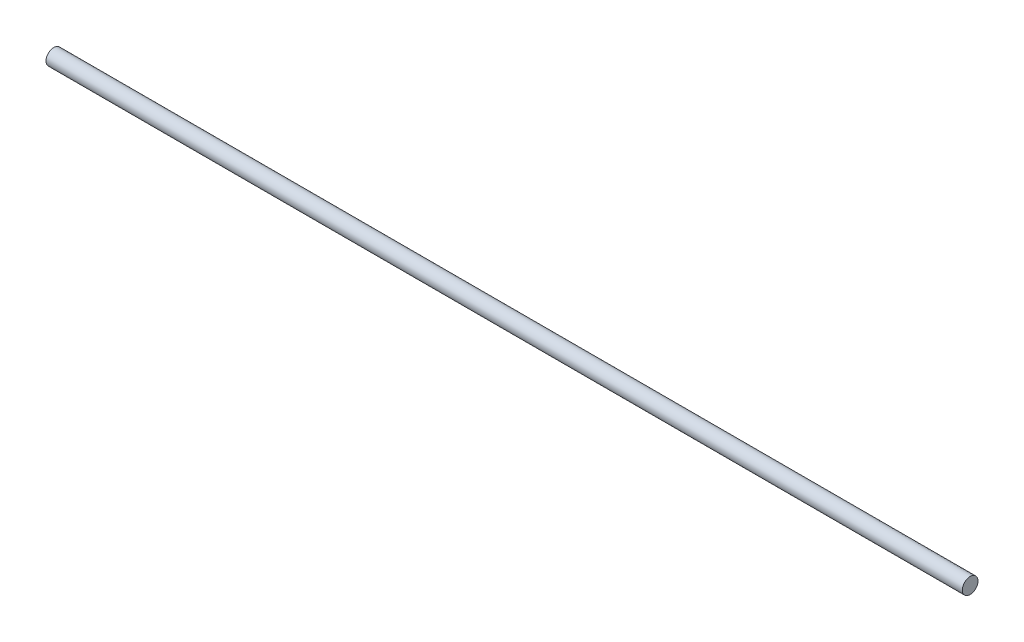
from build123d import *

# Parameters (mm, degrees)
ESQUISSE1_R        = 2.5
BOSS_EXTRU_1_DEPTH = 292


with BuildPart() as part:
    # Esquisse1 → Boss.-Extru.1 (new body)
    with BuildSketch(Plane(origin=(0, 0, 0), x_dir=(0, 0, -1), z_dir=(1, 0, 0))):
        Circle(ESQUISSE1_R)
    extrude(amount=BOSS_EXTRU_1_DEPTH)


solid = part.part
